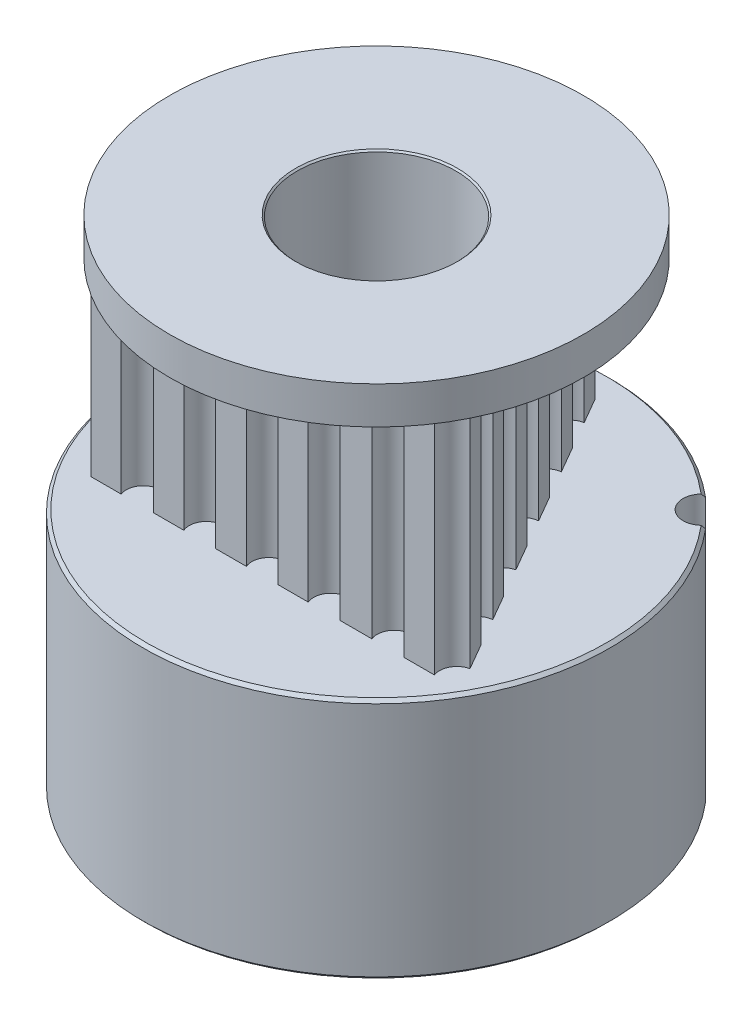
from build123d import *

# Parameters (mm, degrees)
P_IDAT_START            = 7.8
SKICA1_R                = 2.5
P_IDAT_VYSUNUT_M1_DEPTH = 7
SKICA2_R                = 3.5
SKICA2_R_2              = 2.5
P_IDAT_VYSUNUT_M2_DEPTH = 7.8
SKICA3_R                = 3.5
SKICA3_R_2              = 2.5
P_IDAT_VYSUNUT_M3_DEPTH = 1.2
SKICA5_R                = 7.5
SKICA5_R_2              = 3.5
P_IDAT_VYSUNUT_M4_DEPTH = 1.2
SKICA6_R                = 7.5
SKICA6_R_2              = 3.5
P_IDAT_VYSUNUT_M5_DEPTH = 7.8
ZKOSEN_1_SIZE           = 0.1
ZKOSEN_2_SIZE           = 0.1
ZKOSEN_3_SIZE           = 0.1
SKETCH8_OUTSIDE_W       = 22.314
SKETCH8_OUTSIDE_H       = 22.314
SKETCH8_OUTSIDE_R       = 6.65
CUT_EXTRUDE2_DEPTH      = 5
SKETCH32_R              = 6.65
CUT_EXTRUDE3_DEPTH      = 7
BOSS_EXTRUDE1_DEPTH     = 7
SKETCH34_R              = 2.55
CUT_EXTRUDE4_DEPTH      = 30
SKETCH20_R              = 1.5
CUT_EXTRUDE5_DEPTH      = 8
SKETCH19_R              = 1.5
CUT_EXTRUDE6_DEPTH      = 8
SKETCH30_R              = 0.617994848
CUT_EXTRUDE7_DEPTH      = 8


with BuildPart() as part:
    # Skica1 → Přidat vysunutím1 (new body)
    with BuildSketch(Plane(origin=(0, 0, 0), x_dir=(1, 0, 0), z_dir=(0, 1, 0)).offset(P_IDAT_START)):
        with BuildLine():
            ThreePointArc((-5.730143195, 1.098270155), (-5.09645097, 1.530497044), (-5.387174672, 2.240331989))
            ThreePointArc((-5.387174672, 2.240331989), (-5.468060657, 2.292707421), (-5.540463547, 2.356296335))
            ThreePointArc((-5.540463547, 2.356296335), (-5.573874331, 2.399596558), (-5.596043873, 2.44959357))
            ThreePointArc((-5.596043873, 2.44959357), (-5.50369925, 2.650567912), (-5.404139771, 2.848067596))
            ThreePointArc((-5.404139771, 2.848067596), (-5.351227535, 2.86190541), (-5.296542742, 2.862779021))
            ThreePointArc((-5.296542742, 2.862779021), (-5.201685094, 2.845815675), (-5.110305882, 2.815228615))
            ThreePointArc((-5.110305882, 2.815228615), (-4.374063308, 3.030479148), (-4.431206919, 3.795410862))
            ThreePointArc((-4.431206919, 3.795410862), (-4.491949163, 3.870218002), (-4.541158349, 3.953068377))
            ThreePointArc((-4.541158349, 3.953068377), (-4.559553388, 4.004573836), (-4.565187949, 4.058974585))
            ThreePointArc((-4.565187949, 4.058974585), (-4.415258506, 4.221576484), (-4.259541056, 4.378644275))
            ThreePointArc((-4.259541056, 4.378644275), (-4.204942409, 4.375454038), (-4.15266412, 4.359386362))
            ThreePointArc((-4.15266412, 4.359386362), (-4.067691098, 4.313940635), (-3.990236225, 4.256612884))
            ThreePointArc((-3.990236225, 4.256612884), (-3.223511854, 4.233816838), (-3.041481758, 4.978968476))
            ThreePointArc((-3.041481758, 4.978968476), (-3.076134388, 5.06888468), (-3.097332931, 5.162886543))
            ThreePointArc((-3.097332931, 5.162886543), (-3.09891159, 5.217555525), (-3.08745962, 5.271034888))
            ThreePointArc((-3.08745962, 5.271034888), (-2.894621497, 5.379347737), (-2.697988784, 5.480608745))
            ThreePointArc((-2.697988784, 5.480608745), (-2.647048223, 5.460702739), (-2.6022938, 5.429266591))
            ThreePointArc((-2.6022938, 5.429266591), (-2.535523156, 5.359787029), (-2.479574443, 5.281330225))
            ThreePointArc((-2.479574443, 5.281330225), (-1.7574206, 5.022719037), (-1.354035171, 5.675149965))
            ThreePointArc((-1.354035171, 5.675149965), (-1.359206146, 5.771373608), (-1.350318985, 5.867325402))
            ThreePointArc((-1.350318985, 5.867325402), (-1.334926735, 5.919806527), (-1.307509232, 5.967129569))
            ThreePointArc((-1.307509232, 5.967129569), (-1.090638767, 6.010550954), (-0.872338572, 6.046093045))
            ThreePointArc((-0.872338572, 6.046093045), (-0.830042514, 6.01141981), (-0.797192832, 5.967692379))
            ThreePointArc((-0.797192832, 5.967692379), (-0.755160541, 5.880980125), (-0.726194639, 5.789074167))
            ThreePointArc((-0.726194639, 5.789074167), (-0.119300773, 5.319962501), (0.465953812, 5.815808234))
            ThreePointArc((0.465953812, 5.815808234), (0.490770664, 5.908920276), (0.528873591, 5.997429571))
            ThreePointArc((0.528873591, 5.997429571), (0.55973005, 6.04258562), (0.600429269, 6.079120034))
            ThreePointArc((0.600429269, 6.079120034), (0.820103284, 6.053399565), (1.038702217, 6.019743632))
            ThreePointArc((1.038702217, 6.019743632), (1.06821354, 5.973697225), (1.085942924, 5.921958857))
            ThreePointArc((1.085942924, 5.921958857), (1.099122448, 5.826501911), (1.098270155, 5.730143195))
            ThreePointArc((1.098270155, 5.730143195), (1.530497044, 5.09645097), (2.240331989, 5.387174672))
            ThreePointArc((2.240331989, 5.387174672), (2.292707421, 5.468060657), (2.356296335, 5.540463547))
            ThreePointArc((2.356296335, 5.540463547), (2.399596558, 5.573874331), (2.44959357, 5.596043873))
            ThreePointArc((2.44959357, 5.596043873), (2.650567912, 5.50369925), (2.848067596, 5.404139771))
            ThreePointArc((2.848067596, 5.404139771), (2.86190541, 5.351227535), (2.862779021, 5.296542742))
            ThreePointArc((2.862779021, 5.296542742), (2.845815675, 5.201685094), (2.815228615, 5.110305882))
            ThreePointArc((2.815228615, 5.110305882), (3.030479148, 4.374063308), (3.795410862, 4.431206919))
            ThreePointArc((3.795410862, 4.431206919), (3.870218002, 4.491949163), (3.953068377, 4.541158349))
            ThreePointArc((3.953068377, 4.541158349), (4.004573836, 4.559553388), (4.058974585, 4.565187949))
            ThreePointArc((4.058974585, 4.565187949), (4.221576484, 4.415258506), (4.378644275, 4.259541056))
            ThreePointArc((4.378644275, 4.259541056), (4.375454038, 4.204942409), (4.359386362, 4.15266412))
            ThreePointArc((4.359386362, 4.15266412), (4.313940635, 4.067691098), (4.256612884, 3.990236225))
            ThreePointArc((4.256612884, 3.990236225), (4.233816838, 3.223511854), (4.978968476, 3.041481758))
            ThreePointArc((4.978968476, 3.041481758), (5.06888468, 3.076134388), (5.162886543, 3.097332931))
            ThreePointArc((5.162886543, 3.097332931), (5.217555525, 3.09891159), (5.271034888, 3.08745962))
            ThreePointArc((5.271034888, 3.08745962), (5.379347737, 2.894621497), (5.480608745, 2.697988784))
            ThreePointArc((5.480608745, 2.697988784), (5.460702739, 2.647048223), (5.429266591, 2.6022938))
            ThreePointArc((5.429266591, 2.6022938), (5.359787029, 2.535523156), (5.281330225, 2.479574443))
            ThreePointArc((5.281330225, 2.479574443), (5.022719037, 1.7574206), (5.675149965, 1.354035171))
            ThreePointArc((5.675149965, 1.354035171), (5.771373608, 1.359206146), (5.867325402, 1.350318985))
            ThreePointArc((5.867325402, 1.350318985), (5.919806527, 1.334926735), (5.967129569, 1.307509232))
            ThreePointArc((5.967129569, 1.307509232), (6.010550954, 1.090638767), (6.046093045, 0.872338572))
            ThreePointArc((6.046093045, 0.872338572), (6.01141981, 0.830042514), (5.967692379, 0.797192832))
            ThreePointArc((5.967692379, 0.797192832), (5.880980125, 0.755160541), (5.789074167, 0.726194639))
            ThreePointArc((5.789074167, 0.726194639), (5.319962501, 0.119300773), (5.815808234, -0.465953812))
            ThreePointArc((5.815808234, -0.465953812), (5.908920276, -0.490770664), (5.997429571, -0.528873591))
            ThreePointArc((5.997429571, -0.528873591), (6.04258562, -0.55973005), (6.079120034, -0.600429269))
            ThreePointArc((6.079120034, -0.600429269), (6.053399565, -0.820103284), (6.019743632, -1.038702217))
            ThreePointArc((6.019743632, -1.038702217), (5.973697225, -1.06821354), (5.921958857, -1.085942924))
            ThreePointArc((5.921958857, -1.085942924), (5.826501911, -1.099122448), (5.730143195, -1.098270155))
            ThreePointArc((5.730143195, -1.098270155), (5.09645097, -1.530497044), (5.387174672, -2.240331989))
            ThreePointArc((5.387174672, -2.240331989), (5.468060657, -2.292707421), (5.540463547, -2.356296335))
            ThreePointArc((5.540463547, -2.356296335), (5.573874331, -2.399596558), (5.596043873, -2.44959357))
            ThreePointArc((5.596043873, -2.44959357), (5.50369925, -2.650567911), (5.404139771, -2.848067596))
            ThreePointArc((5.404139771, -2.848067596), (5.351227535, -2.86190541), (5.296542742, -2.862779021))
            ThreePointArc((5.296542742, -2.862779021), (5.201685094, -2.845815675), (5.110305882, -2.815228615))
            ThreePointArc((5.110305882, -2.815228615), (4.374063308, -3.030479148), (4.431206919, -3.795410862))
            ThreePointArc((4.431206919, -3.795410862), (4.491949163, -3.870218002), (4.541158349, -3.953068377))
            ThreePointArc((4.541158349, -3.953068377), (4.559553388, -4.004573836), (4.565187949, -4.058974585))
            ThreePointArc((4.565187949, -4.058974585), (4.415258506, -4.221576484), (4.259541056, -4.378644275))
            ThreePointArc((4.259541056, -4.378644275), (4.204942409, -4.375454038), (4.15266412, -4.359386362))
            ThreePointArc((4.15266412, -4.359386362), (4.067691098, -4.313940635), (3.990236225, -4.256612884))
            ThreePointArc((3.990236225, -4.256612884), (3.223511854, -4.233816838), (3.041481758, -4.978968476))
            ThreePointArc((3.041481758, -4.978968476), (3.076134388, -5.06888468), (3.097332931, -5.162886543))
            ThreePointArc((3.097332931, -5.162886543), (3.09891159, -5.217555525), (3.08745962, -5.271034888))
            ThreePointArc((3.08745962, -5.271034888), (2.894621497, -5.379347737), (2.697988784, -5.480608745))
            ThreePointArc((2.697988784, -5.480608745), (2.647048223, -5.460702739), (2.6022938, -5.429266591))
            ThreePointArc((2.6022938, -5.429266591), (2.535523156, -5.359787029), (2.479574443, -5.281330225))
            ThreePointArc((2.479574443, -5.281330225), (1.7574206, -5.022719037), (1.354035171, -5.675149965))
            ThreePointArc((1.354035171, -5.675149965), (1.359206146, -5.771373608), (1.350318985, -5.867325402))
            ThreePointArc((1.350318985, -5.867325402), (1.334926735, -5.919806527), (1.307509232, -5.967129569))
            ThreePointArc((1.307509232, -5.967129569), (1.090638767, -6.010550954), (0.872338572, -6.046093045))
            ThreePointArc((0.872338572, -6.046093045), (0.830042514, -6.01141981), (0.797192832, -5.967692379))
            ThreePointArc((0.797192832, -5.967692379), (0.755160541, -5.880980125), (0.726194639, -5.789074167))
            ThreePointArc((0.726194639, -5.789074167), (0.119300773, -5.319962501), (-0.465953812, -5.815808234))
            ThreePointArc((-0.465953812, -5.815808234), (-0.490770664, -5.908920276), (-0.528873591, -5.997429571))
            ThreePointArc((-0.528873591, -5.997429571), (-0.55973005, -6.04258562), (-0.600429269, -6.079120034))
            ThreePointArc((-0.600429269, -6.079120034), (-0.820103284, -6.053399565), (-1.038702217, -6.019743632))
            ThreePointArc((-1.038702217, -6.019743632), (-1.06821354, -5.973697225), (-1.085942924, -5.921958857))
            ThreePointArc((-1.085942924, -5.921958857), (-1.099122448, -5.826501911), (-1.098270155, -5.730143195))
            ThreePointArc((-1.098270155, -5.730143195), (-1.530497044, -5.09645097), (-2.240331989, -5.387174672))
            ThreePointArc((-2.240331989, -5.387174672), (-2.292707421, -5.468060657), (-2.356296335, -5.540463547))
            ThreePointArc((-2.356296335, -5.540463547), (-2.399596558, -5.573874331), (-2.44959357, -5.596043873))
            ThreePointArc((-2.44959357, -5.596043873), (-2.650567912, -5.50369925), (-2.848067596, -5.404139771))
            ThreePointArc((-2.848067596, -5.404139771), (-2.86190541, -5.351227535), (-2.862779021, -5.296542742))
            ThreePointArc((-2.862779021, -5.296542742), (-2.845815675, -5.201685094), (-2.815228615, -5.110305882))
            ThreePointArc((-2.815228615, -5.110305882), (-3.030479148, -4.374063308), (-3.795410862, -4.431206919))
            ThreePointArc((-3.795410862, -4.431206919), (-3.870218002, -4.491949163), (-3.953068377, -4.541158349))
            ThreePointArc((-3.953068377, -4.541158349), (-4.004573836, -4.559553388), (-4.058974585, -4.565187949))
            ThreePointArc((-4.058974585, -4.565187949), (-4.221576484, -4.415258506), (-4.378644275, -4.259541056))
            ThreePointArc((-4.378644275, -4.259541056), (-4.375454038, -4.204942409), (-4.359386362, -4.15266412))
            ThreePointArc((-4.359386362, -4.15266412), (-4.313940635, -4.067691098), (-4.256612884, -3.990236225))
            ThreePointArc((-4.256612884, -3.990236225), (-4.233816838, -3.223511854), (-4.978968476, -3.041481758))
            ThreePointArc((-4.978968476, -3.041481758), (-5.06888468, -3.076134388), (-5.162886543, -3.097332931))
            ThreePointArc((-5.162886543, -3.097332931), (-5.217555525, -3.09891159), (-5.271034888, -3.08745962))
            ThreePointArc((-5.271034888, -3.08745962), (-5.379347737, -2.894621497), (-5.480608745, -2.697988784))
            ThreePointArc((-5.480608745, -2.697988784), (-5.460702739, -2.647048223), (-5.429266591, -2.6022938))
            ThreePointArc((-5.429266591, -2.6022938), (-5.359787029, -2.535523156), (-5.281330225, -2.479574443))
            ThreePointArc((-5.281330225, -2.479574443), (-5.022719037, -1.7574206), (-5.675149965, -1.354035171))
            ThreePointArc((-5.675149965, -1.354035171), (-5.771373608, -1.359206146), (-5.867325402, -1.350318985))
            ThreePointArc((-5.867325402, -1.350318985), (-5.919806527, -1.334926735), (-5.967129569, -1.307509232))
            ThreePointArc((-5.967129569, -1.307509232), (-6.010550954, -1.090638767), (-6.046093045, -0.872338572))
            ThreePointArc((-6.046093045, -0.872338572), (-6.01141981, -0.830042514), (-5.967692379, -0.797192832))
            ThreePointArc((-5.967692379, -0.797192832), (-5.880980125, -0.755160541), (-5.789074167, -0.726194639))
            ThreePointArc((-5.789074167, -0.726194639), (-5.319962501, -0.119300773), (-5.815808234, 0.465953812))
            ThreePointArc((-5.815808234, 0.465953812), (-5.908920276, 0.490770664), (-5.997429571, 0.528873591))
            ThreePointArc((-5.997429571, 0.528873591), (-6.04258562, 0.55973005), (-6.079120034, 0.600429269))
            ThreePointArc((-6.079120034, 0.600429269), (-6.053399565, 0.820103284), (-6.019743632, 1.038702217))
            ThreePointArc((-6.019743632, 1.038702217), (-5.973697225, 1.06821354), (-5.921958857, 1.085942924))
            ThreePointArc((-5.921958857, 1.085942924), (-5.826501911, 1.099122448), (-5.730143195, 1.098270155))
        make_face()
        Circle(SKICA1_R, mode=Mode.SUBTRACT)
    extrude(amount=P_IDAT_VYSUNUT_M1_DEPTH)

    # Skica2 → Přidat vysunutím2 (add)
    with BuildSketch(Plane.XZ.offset(-7.8)):
        Circle(SKICA2_R)
        Circle(SKICA2_R_2, mode=Mode.SUBTRACT)
    extrude(amount=P_IDAT_VYSUNUT_M2_DEPTH)

    # Skica3 → Přidat vysunutím3 (add)
    with BuildSketch(Plane(origin=(0, 14.8, 0), x_dir=(1, 0, 0), z_dir=(0, 1, 0))):
        Circle(SKICA3_R)
        Circle(SKICA3_R_2, mode=Mode.SUBTRACT)
    extrude(amount=P_IDAT_VYSUNUT_M3_DEPTH)

    # Zkosení2
    zkosen_2_edges = [part.edges().sort_by_distance(p)[0] for p in [
        (-2.5, 0, 0),
        (-2.5, 16, 0),
    ]]
    chamfer(zkosen_2_edges, length=ZKOSEN_2_SIZE)

    # Sketch32 → Cut-Extrude3 (cut)
    with BuildSketch(Plane(origin=(0, 7.8, 0), x_dir=(1, 0, 0), z_dir=(0, 1, 0))):
        Circle(SKETCH32_R)
    extrude(amount=CUT_EXTRUDE3_DEPTH, mode=Mode.SUBTRACT)



with BuildPart() as body_2:
    # Skica5 → Přidat vysunutím4 (new body)
    with BuildSketch(Plane(origin=(0, 16, 0), x_dir=(1, 0, 0), z_dir=(0, 1, 0))):
        Circle(SKICA5_R)
        Circle(SKICA5_R_2, mode=Mode.SUBTRACT)
    extrude(amount=-P_IDAT_VYSUNUT_M4_DEPTH)

    # Zkosení1
    zkosen_1_edges = [body_2.edges().sort_by_distance(p)[0] for p in [
        (-7.5, 16, 0),
        (-7.5, 14.8, 0),
    ]]
    chamfer(zkosen_1_edges, length=ZKOSEN_1_SIZE)

    # Sketch8 outside → Cut-Extrude2 (cut)
    with BuildSketch(Plane(origin=(0, 16, 0), x_dir=(1, 0, 0), z_dir=(0, 1, 0))):
        Rectangle(SKETCH8_OUTSIDE_W, SKETCH8_OUTSIDE_H)
        Circle(SKETCH8_OUTSIDE_R, mode=Mode.SUBTRACT)
    extrude(amount=-CUT_EXTRUDE2_DEPTH, mode=Mode.SUBTRACT)


with BuildPart() as body_3:
    # Skica6 → Přidat vysunutím5 (new body)
    with BuildSketch(Plane.XZ):
        Circle(SKICA6_R)
        Circle(SKICA6_R_2, mode=Mode.SUBTRACT)
    extrude(amount=-P_IDAT_VYSUNUT_M5_DEPTH)

    # Zkosení3
    zkosen_3_edges = [body_3.edges().sort_by_distance(p)[0] for p in [
        (-7.5, 0, 0),
        (-7.5, 7.8, 0),
    ]]
    chamfer(zkosen_3_edges, length=ZKOSEN_3_SIZE)


with BuildPart() as part_1:
    add(part.part)

    add(body_2.part)  # Boss-Extrude1 merges body 2

    add(body_3.part)  # Boss-Extrude1 merges body 3
    # Sketch25 → Boss-Extrude1 (add)
    with BuildSketch(Plane(origin=(0, 7.8, 0), x_dir=(1, 0, 0), z_dir=(0, 1, 0))):
        with BuildLine():
            Line((-0.717938034, 6.096494849), (-0.907057907, 5.768929619))
            ThreePointArc((-0.907057907, 5.768929619), (-0.50810169, 4.942474166), (-1.423311217, 4.874752658))
            Line((-1.423311217, 4.874752658), (-1.918483232, 4.017089569))
            ThreePointArc((-1.918483232, 4.017089569), (-1.536908146, 3.193503192), (-2.440942413, 3.112163722))
            Line((-2.440942413, 3.112163722), (-2.91615597, 2.289069697))
            ThreePointArc((-2.91615597, 2.289069697), (-2.524743358, 1.463789867), (-3.435162962, 1.390123218))
            Line((-3.435162962, 1.390123218), (-3.927672168, 0.53707225))
            ThreePointArc((-3.927672168, 0.53707225), (-3.52415558, -0.290042476), (-4.442216238, -0.354144223))
            Line((-4.442216238, -0.354144223), (-4.911986074, -1.167809446))
            ThreePointArc((-4.911986074, -1.167809446), (-4.535840997, -1.990382794), (-5.436282951, -2.075918275))
            Line((-5.436282951, -2.075918275), (-5.898945462, -2.877273251))
            ThreePointArc((-5.898945462, -2.877273251), (-5.507068696, -3.176777484), (-5.508386199, -3.67))
            Line((-5.508386199, -3.67), (-4.536814361, -3.67))
            ThreePointArc((-4.536814361, -3.67), (-4.017748656, -2.91854188), (-3.49868295, -3.67))
            Line((-3.49868295, -3.67), (-2.520776964, -3.67))
            ThreePointArc((-2.520776964, -3.67), (-2.009979522, -2.897949376), (-1.499182081, -3.67))
            Line((-1.499182081, -3.67), (-0.513007831, -3.67))
            ThreePointArc((-0.513007831, -3.67), (-0.002210389, -2.897949376), (0.508587053, -3.67))
            Line((0.508587053, -3.67), (1.474168799, -3.67))
            ThreePointArc((1.474168799, -3.67), (1.98496624, -2.897949376), (2.495763682, -3.67))
            Line((2.495763682, -3.67), (3.518869287, -3.67))
            ThreePointArc((3.518869287, -3.67), (4.033920381, -2.908245628), (4.548971475, -3.67))
            Line((4.548971475, -3.67), (5.530558251, -3.67))
            ThreePointArc((5.530558251, -3.67), (5.556358411, -3.205925047), (5.92604395, -2.92420921))
            Line((5.92604395, -2.92420921), (5.4337836, -2.071589272))
            ThreePointArc((5.4337836, -2.071589272), (4.505290561, -2.021283953), (4.925971396, -1.192032735))
            Line((4.925971396, -1.192032735), (4.445945351, -0.360603235))
            ThreePointArc((4.445945351, -0.360603235), (3.569336636, -0.24921119), (3.911172652, 0.565650249))
            Line((3.911172652, 0.565650249), (3.418477875, 1.419022635))
            ThreePointArc((3.418477875, 1.419022635), (2.483630084, 1.460464645), (2.915164146, 2.290787587))
            Line((2.915164146, 2.290787587), (2.427366725, 3.135677503))
            ThreePointArc((2.427366725, 3.135677503), (1.503804697, 3.192615402), (1.916276044, 4.02091253))
            Line((1.916276044, 4.02091253), (1.436397938, 4.852085792))
            ThreePointArc((1.436397938, 4.852085792), (0.532106306, 4.93312138), (0.914073244, 5.7567787))
            Line((0.914073244, 5.7567787), (0.432060736, 6.591648854))
            ThreePointArc((0.432060736, 6.591648854), (0, 6.385), (-0.432060736, 6.591648854))
            Line((-0.432060736, 6.591648854), (-0.717938034, 6.096494849))
        make_face()
    extrude(amount=BOSS_EXTRUDE1_DEPTH)

    # Sketch34 → Cut-Extrude4 (cut)
    with BuildSketch(Plane(origin=(0, 16, 0), x_dir=(1, 0, 0), z_dir=(0, 1, 0))):
        Circle(SKETCH34_R)
    extrude(amount=-CUT_EXTRUDE4_DEPTH, mode=Mode.SUBTRACT)

    # Sketch20 → Cut-Extrude5 (cut)
    with BuildSketch(Plane.ZY.offset(7.5)):
        with Locations((0, 3.9)):
            Circle(SKETCH20_R)
    extrude(amount=-CUT_EXTRUDE5_DEPTH, mode=Mode.SUBTRACT)

    # Sketch19 → Cut-Extrude6 (cut)
    with BuildSketch(Plane(origin=(0, 0, -7.5), x_dir=(-1, 0, 0), z_dir=(0, 0, -1))):
        with Locations((0, 3.9)):
            Circle(SKETCH19_R)
    extrude(amount=-CUT_EXTRUDE6_DEPTH, mode=Mode.SUBTRACT)

    # Sketch30 → Cut-Extrude7 (cut)
    with BuildSketch(Plane.XZ):
        with Locations((5.232590181, -5.232590181)):
            Circle(SKETCH30_R)
    extrude(amount=-CUT_EXTRUDE7_DEPTH, mode=Mode.SUBTRACT)


solid = part_1.part
